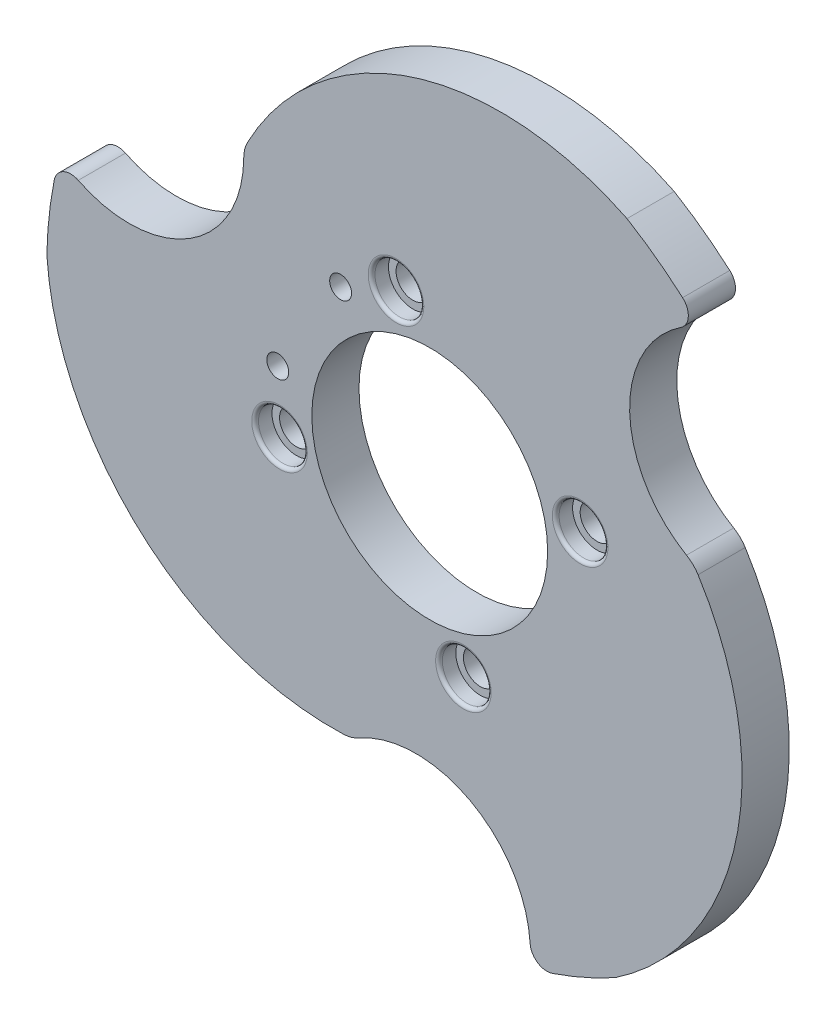
from build123d import *

# Parameters (mm, degrees)
SKETCH4_R             = 3.25
SKETCH4_R_2           = 5
SKETCH4_R_3           = 35
BOSS_EXTRUDE2_DEPTH   = 14
ESBO_O3_R             = 7.25
CORTE_EXTRUS_O1_DEPTH = 5
FILETE2_R             = 1


with BuildPart() as part:
    # Sketch4 → Boss-Extrude2 (new body)
    with BuildSketch(Plane.XY):
        with BuildLine():
            ThreePointArc((135.711956254, 40.012906067), (133.498311811, 39.078606258), (131.125704093, 38.699303642))
            ThreePointArc((131.125704093, 38.699303642), (71.046587381, 60.439214017), (43.082934706, 117.886216524))
            ThreePointArc((43.082934706, 117.886216524), (43.723303204, 128.09951793), (45.279720546, 138.213822774))
            ThreePointArc((45.279720546, 138.213822774), (47.980485983, 141.720753121), (52.406835354, 141.709543754))
            ThreePointArc((52.406835354, 141.709543754), (85.380644245, 143.225752695), (101.518008582, 172.020829263))
            ThreePointArc((101.518008582, 172.020829263), (101.815703435, 174.405051491), (102.673521593, 176.649441355))
            ThreePointArc((102.673521593, 176.649441355), (151.540394609, 217.809527477), (215.272784489, 213.303259824))
            ThreePointArc((215.272784489, 213.303259824), (223.797578714, 207.642033733), (231.77861498, 201.236984354))
            ThreePointArc((231.77861498, 201.236984354), (233.465323031, 197.144587703), (231.242440749, 193.316861385))
            ThreePointArc((231.242440749, 193.316861385), (216.068611764, 164.002600755), (232.937197408, 135.629695005))
            ThreePointArc((232.937197408, 135.629695005), (234.853146998, 134.179772586), (236.367936558, 132.314685337))
            ThreePointArc((236.367936558, 132.314685337), (247.580180254, 69.414688841), (211.811443049, 16.473953987))
            ThreePointArc((211.811443049, 16.473953987), (202.646280326, 11.921878672), (193.108826719, 8.212623207))
            ThreePointArc((193.108826719, 8.212623207), (188.72135323, 8.798089511), (186.517886141, 12.637025196))
            ThreePointArc((186.517886141, 12.637025196), (168.717906235, 40.435076885), (135.711956254, 40.012906067))
        make_face()
        with Locations((111.625067893, 123.588087508)):
            Circle(SKETCH4_R, mode=Mode.SUBTRACT)
        with Locations((146.721161104, 160.531263969)):
            Circle(SKETCH4_R_2, mode=Mode.SUBTRACT)
        with Locations((112.146853607, 105.588087508)):
            Circle(SKETCH4_R_2, mode=Mode.SUBTRACT)
        with Locations((166.723613726, 71.244356255)):
            Circle(SKETCH4_R_2, mode=Mode.SUBTRACT)
        with Locations((130.273826669, 153.217907011)):
            Circle(SKETCH4_R, mode=Mode.SUBTRACT)
        with Locations((201.365841272, 125.889036422)):
            Circle(SKETCH4_R_2, mode=Mode.SUBTRACT)
        with Locations((156.722387415, 115.887810112)):
            Circle(SKETCH4_R_3, mode=Mode.SUBTRACT)
    extrude(amount=BOSS_EXTRUDE2_DEPTH)

    # Esboço3 → Corte-extrusão1 (cut)
    with BuildSketch(Plane.XY.offset(14)):
        with Locations((201.365841272, 125.889036422)):
            Circle(ESBO_O3_R)
        with Locations((146.721161104, 160.531263969)):
            Circle(ESBO_O3_R)
        with Locations((112.146853607, 105.588087508)):
            Circle(ESBO_O3_R)
        with Locations((166.723613726, 71.244356255)):
            Circle(ESBO_O3_R)
    extrude(amount=-CORTE_EXTRUS_O1_DEPTH, mode=Mode.SUBTRACT)

    # Filete2
    filete2_edges = [part.edges().sort_by_distance(p)[0] for p in [
        (194.115841272, 125.889036422, 14),
        (139.471161104, 160.531263969, 14),
        (104.896853607, 105.588087508, 14),
        (159.473613726, 71.244356255, 14),
    ]]
    fillet(filete2_edges, radius=FILETE2_R)


solid = part.part
